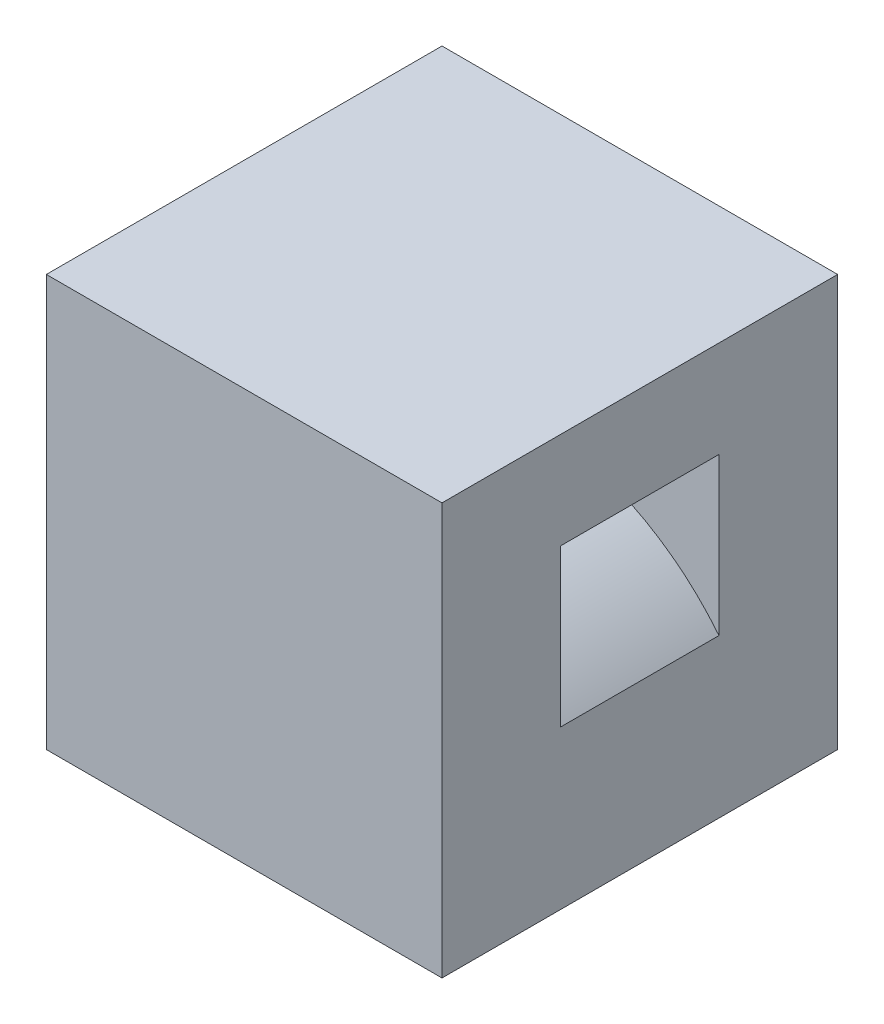
from build123d import *

# Parameters (mm, degrees)
SKETCH1_W           = 31.75
SKETCH1_H           = 33.02
BOSS_EXTRUDE1_DEPTH = 31.75
CUT_EXTRUDE1_START  = 3.175
SKETCH1_3_W         = 25.4
SKETCH1_3_H         = 12.7
CUT_EXTRUDE1_DEPTH  = 25.4
CUT_EXTRUDE2_START  = 9.525
CUT_EXTRUDE2_DEPTH  = 12.7


with BuildPart() as part:
    # Sketch1 → Boss-Extrude1 (new body)
    with BuildSketch(Plane.XY):
        Rectangle(SKETCH1_W, SKETCH1_H)
    extrude(amount=BOSS_EXTRUDE1_DEPTH)

    # Sketch1_3 → Cut-Extrude1 (cut)
    with BuildSketch(Plane.XY.offset(CUT_EXTRUDE1_START)):
        with Locations((0, -10.16)):
            Rectangle(SKETCH1_3_W, SKETCH1_3_H)
    extrude(amount=CUT_EXTRUDE1_DEPTH, mode=Mode.SUBTRACT)

    # Sketch1_4 → Cut-Extrude2 (cut)
    with BuildSketch(Plane.XY.offset(CUT_EXTRUDE2_START)):
        with BuildLine():
            Line((-15.875, 8.762680903), (-15.875, -3.825884934))
            ThreePointArc((-15.875, -3.825884934), (0, 3.81), (15.875, -3.825884934))
            Line((15.875, -3.825884934), (15.875, 8.762680903))
            ThreePointArc((15.875, 8.762680903), (0, 13.335), (-15.875, 8.762680903))
        make_face()
    extrude(amount=CUT_EXTRUDE2_DEPTH, mode=Mode.SUBTRACT)


solid = part.part
